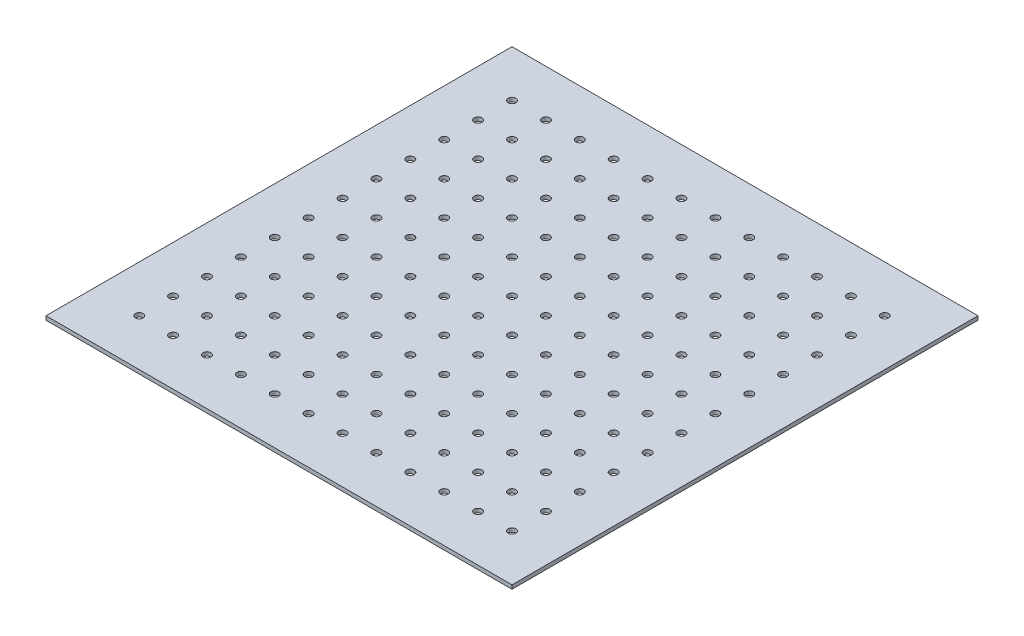
from build123d import *

# Parameters (mm, degrees)
SKETCH1_W           = 381
SKETCH1_H           = 381
SKETCH1_R           = 3.175
BOSS_EXTRUDE1_DEPTH = 3.175


with BuildPart() as part:
    # Sketch1 → Boss-Extrude1 (new body)
    with BuildSketch(Plane(origin=(0, 0, 0), x_dir=(1, 0, 0), z_dir=(0, 1, 0))):
        Rectangle(SKETCH1_W, SKETCH1_H)
        with Locations((-152.4, 152.4)):
            Circle(SKETCH1_R, mode=Mode.SUBTRACT)
        with Locations((-124.690909091, 152.4)):
            Circle(SKETCH1_R, mode=Mode.SUBTRACT)
        with Locations((-96.981818182, 152.4)):
            Circle(SKETCH1_R, mode=Mode.SUBTRACT)
        with Locations((-69.272727273, 152.4)):
            Circle(SKETCH1_R, mode=Mode.SUBTRACT)
        with Locations((-41.563636364, 152.4)):
            Circle(SKETCH1_R, mode=Mode.SUBTRACT)
        with Locations((-13.854545455, 152.4)):
            Circle(SKETCH1_R, mode=Mode.SUBTRACT)
        with Locations((13.854545455, 152.4)):
            Circle(SKETCH1_R, mode=Mode.SUBTRACT)
        with Locations((41.563636364, 152.4)):
            Circle(SKETCH1_R, mode=Mode.SUBTRACT)
        with Locations((69.272727273, 152.4)):
            Circle(SKETCH1_R, mode=Mode.SUBTRACT)
        with Locations((96.981818182, 152.4)):
            Circle(SKETCH1_R, mode=Mode.SUBTRACT)
        with Locations((124.690909091, 152.4)):
            Circle(SKETCH1_R, mode=Mode.SUBTRACT)
        with Locations((152.4, 152.4)):
            Circle(SKETCH1_R, mode=Mode.SUBTRACT)
        with Locations((-124.690909091, 124.690909091)):
            Circle(SKETCH1_R, mode=Mode.SUBTRACT)
        with Locations((-96.981818182, 124.690909091)):
            Circle(SKETCH1_R, mode=Mode.SUBTRACT)
        with Locations((-69.272727273, 124.690909091)):
            Circle(SKETCH1_R, mode=Mode.SUBTRACT)
        with Locations((-41.563636364, 124.690909091)):
            Circle(SKETCH1_R, mode=Mode.SUBTRACT)
        with Locations((-13.854545455, 124.690909091)):
            Circle(SKETCH1_R, mode=Mode.SUBTRACT)
        with Locations((13.854545455, 124.690909091)):
            Circle(SKETCH1_R, mode=Mode.SUBTRACT)
        with Locations((41.563636364, 124.690909091)):
            Circle(SKETCH1_R, mode=Mode.SUBTRACT)
        with Locations((69.272727273, 124.690909091)):
            Circle(SKETCH1_R, mode=Mode.SUBTRACT)
        with Locations((96.981818182, 124.690909091)):
            Circle(SKETCH1_R, mode=Mode.SUBTRACT)
        with Locations((124.690909091, 124.690909091)):
            Circle(SKETCH1_R, mode=Mode.SUBTRACT)
        with Locations((152.4, 124.690909091)):
            Circle(SKETCH1_R, mode=Mode.SUBTRACT)
        with Locations((-124.690909091, 96.981818182)):
            Circle(SKETCH1_R, mode=Mode.SUBTRACT)
        with Locations((-96.981818182, 96.981818182)):
            Circle(SKETCH1_R, mode=Mode.SUBTRACT)
        with Locations((-69.272727273, 96.981818182)):
            Circle(SKETCH1_R, mode=Mode.SUBTRACT)
        with Locations((-41.563636364, 96.981818182)):
            Circle(SKETCH1_R, mode=Mode.SUBTRACT)
        with Locations((-13.854545455, 96.981818182)):
            Circle(SKETCH1_R, mode=Mode.SUBTRACT)
        with Locations((13.854545455, 96.981818182)):
            Circle(SKETCH1_R, mode=Mode.SUBTRACT)
        with Locations((41.563636364, 96.981818182)):
            Circle(SKETCH1_R, mode=Mode.SUBTRACT)
        with Locations((69.272727273, 96.981818182)):
            Circle(SKETCH1_R, mode=Mode.SUBTRACT)
        with Locations((96.981818182, 96.981818182)):
            Circle(SKETCH1_R, mode=Mode.SUBTRACT)
        with Locations((124.690909091, 96.981818182)):
            Circle(SKETCH1_R, mode=Mode.SUBTRACT)
        with Locations((152.4, 96.981818182)):
            Circle(SKETCH1_R, mode=Mode.SUBTRACT)
        with Locations((-124.690909091, 69.272727273)):
            Circle(SKETCH1_R, mode=Mode.SUBTRACT)
        with Locations((-96.981818182, 69.272727273)):
            Circle(SKETCH1_R, mode=Mode.SUBTRACT)
        with Locations((-69.272727273, 69.272727273)):
            Circle(SKETCH1_R, mode=Mode.SUBTRACT)
        with Locations((-41.563636364, 69.272727273)):
            Circle(SKETCH1_R, mode=Mode.SUBTRACT)
        with Locations((-13.854545455, 69.272727273)):
            Circle(SKETCH1_R, mode=Mode.SUBTRACT)
        with Locations((13.854545455, 69.272727273)):
            Circle(SKETCH1_R, mode=Mode.SUBTRACT)
        with Locations((41.563636364, 69.272727273)):
            Circle(SKETCH1_R, mode=Mode.SUBTRACT)
        with Locations((69.272727273, 69.272727273)):
            Circle(SKETCH1_R, mode=Mode.SUBTRACT)
        with Locations((96.981818182, 69.272727273)):
            Circle(SKETCH1_R, mode=Mode.SUBTRACT)
        with Locations((124.690909091, 69.272727273)):
            Circle(SKETCH1_R, mode=Mode.SUBTRACT)
        with Locations((152.4, 69.272727273)):
            Circle(SKETCH1_R, mode=Mode.SUBTRACT)
        with Locations((-124.690909091, 41.563636364)):
            Circle(SKETCH1_R, mode=Mode.SUBTRACT)
        with Locations((-96.981818182, 41.563636364)):
            Circle(SKETCH1_R, mode=Mode.SUBTRACT)
        with Locations((-69.272727273, 41.563636364)):
            Circle(SKETCH1_R, mode=Mode.SUBTRACT)
        with Locations((-41.563636364, 41.563636364)):
            Circle(SKETCH1_R, mode=Mode.SUBTRACT)
        with Locations((-13.854545455, 41.563636364)):
            Circle(SKETCH1_R, mode=Mode.SUBTRACT)
        with Locations((13.854545455, 41.563636364)):
            Circle(SKETCH1_R, mode=Mode.SUBTRACT)
        with Locations((41.563636364, 41.563636364)):
            Circle(SKETCH1_R, mode=Mode.SUBTRACT)
        with Locations((69.272727273, 41.563636364)):
            Circle(SKETCH1_R, mode=Mode.SUBTRACT)
        with Locations((96.981818182, 41.563636364)):
            Circle(SKETCH1_R, mode=Mode.SUBTRACT)
        with Locations((124.690909091, 41.563636364)):
            Circle(SKETCH1_R, mode=Mode.SUBTRACT)
        with Locations((152.4, 41.563636364)):
            Circle(SKETCH1_R, mode=Mode.SUBTRACT)
        with Locations((-124.690909091, 13.854545455)):
            Circle(SKETCH1_R, mode=Mode.SUBTRACT)
        with Locations((-96.981818182, 13.854545455)):
            Circle(SKETCH1_R, mode=Mode.SUBTRACT)
        with Locations((-69.272727273, 13.854545455)):
            Circle(SKETCH1_R, mode=Mode.SUBTRACT)
        with Locations((-41.563636364, 13.854545455)):
            Circle(SKETCH1_R, mode=Mode.SUBTRACT)
        with Locations((-13.854545455, 13.854545455)):
            Circle(SKETCH1_R, mode=Mode.SUBTRACT)
        with Locations((13.854545455, 13.854545455)):
            Circle(SKETCH1_R, mode=Mode.SUBTRACT)
        with Locations((41.563636364, 13.854545455)):
            Circle(SKETCH1_R, mode=Mode.SUBTRACT)
        with Locations((69.272727273, 13.854545455)):
            Circle(SKETCH1_R, mode=Mode.SUBTRACT)
        with Locations((96.981818182, 13.854545455)):
            Circle(SKETCH1_R, mode=Mode.SUBTRACT)
        with Locations((124.690909091, 13.854545455)):
            Circle(SKETCH1_R, mode=Mode.SUBTRACT)
        with Locations((152.4, 13.854545455)):
            Circle(SKETCH1_R, mode=Mode.SUBTRACT)
        with Locations((-124.690909091, -13.854545455)):
            Circle(SKETCH1_R, mode=Mode.SUBTRACT)
        with Locations((-96.981818182, -13.854545455)):
            Circle(SKETCH1_R, mode=Mode.SUBTRACT)
        with Locations((-69.272727273, -13.854545455)):
            Circle(SKETCH1_R, mode=Mode.SUBTRACT)
        with Locations((-41.563636364, -13.854545455)):
            Circle(SKETCH1_R, mode=Mode.SUBTRACT)
        with Locations((-13.854545455, -13.854545455)):
            Circle(SKETCH1_R, mode=Mode.SUBTRACT)
        with Locations((13.854545455, -13.854545455)):
            Circle(SKETCH1_R, mode=Mode.SUBTRACT)
        with Locations((41.563636364, -13.854545455)):
            Circle(SKETCH1_R, mode=Mode.SUBTRACT)
        with Locations((69.272727273, -13.854545455)):
            Circle(SKETCH1_R, mode=Mode.SUBTRACT)
        with Locations((96.981818182, -13.854545455)):
            Circle(SKETCH1_R, mode=Mode.SUBTRACT)
        with Locations((124.690909091, -13.854545455)):
            Circle(SKETCH1_R, mode=Mode.SUBTRACT)
        with Locations((152.4, -13.854545455)):
            Circle(SKETCH1_R, mode=Mode.SUBTRACT)
        with Locations((-124.690909091, -41.563636364)):
            Circle(SKETCH1_R, mode=Mode.SUBTRACT)
        with Locations((-96.981818182, -41.563636364)):
            Circle(SKETCH1_R, mode=Mode.SUBTRACT)
        with Locations((-69.272727273, -41.563636364)):
            Circle(SKETCH1_R, mode=Mode.SUBTRACT)
        with Locations((-41.563636364, -41.563636364)):
            Circle(SKETCH1_R, mode=Mode.SUBTRACT)
        with Locations((-13.854545455, -41.563636364)):
            Circle(SKETCH1_R, mode=Mode.SUBTRACT)
        with Locations((13.854545455, -41.563636364)):
            Circle(SKETCH1_R, mode=Mode.SUBTRACT)
        with Locations((41.563636364, -41.563636364)):
            Circle(SKETCH1_R, mode=Mode.SUBTRACT)
        with Locations((69.272727273, -41.563636364)):
            Circle(SKETCH1_R, mode=Mode.SUBTRACT)
        with Locations((96.981818182, -41.563636364)):
            Circle(SKETCH1_R, mode=Mode.SUBTRACT)
        with Locations((124.690909091, -41.563636364)):
            Circle(SKETCH1_R, mode=Mode.SUBTRACT)
        with Locations((152.4, -41.563636364)):
            Circle(SKETCH1_R, mode=Mode.SUBTRACT)
        with Locations((-124.690909091, -69.272727273)):
            Circle(SKETCH1_R, mode=Mode.SUBTRACT)
        with Locations((-96.981818182, -69.272727273)):
            Circle(SKETCH1_R, mode=Mode.SUBTRACT)
        with Locations((-69.272727273, -69.272727273)):
            Circle(SKETCH1_R, mode=Mode.SUBTRACT)
        with Locations((-41.563636364, -69.272727273)):
            Circle(SKETCH1_R, mode=Mode.SUBTRACT)
        with Locations((-13.854545455, -69.272727273)):
            Circle(SKETCH1_R, mode=Mode.SUBTRACT)
        with Locations((13.854545455, -69.272727273)):
            Circle(SKETCH1_R, mode=Mode.SUBTRACT)
        with Locations((41.563636364, -69.272727273)):
            Circle(SKETCH1_R, mode=Mode.SUBTRACT)
        with Locations((69.272727273, -69.272727273)):
            Circle(SKETCH1_R, mode=Mode.SUBTRACT)
        with Locations((96.981818182, -69.272727273)):
            Circle(SKETCH1_R, mode=Mode.SUBTRACT)
        with Locations((124.690909091, -69.272727273)):
            Circle(SKETCH1_R, mode=Mode.SUBTRACT)
        with Locations((152.4, -69.272727273)):
            Circle(SKETCH1_R, mode=Mode.SUBTRACT)
        with Locations((-124.690909091, -96.981818182)):
            Circle(SKETCH1_R, mode=Mode.SUBTRACT)
        with Locations((-96.981818182, -96.981818182)):
            Circle(SKETCH1_R, mode=Mode.SUBTRACT)
        with Locations((-69.272727273, -96.981818182)):
            Circle(SKETCH1_R, mode=Mode.SUBTRACT)
        with Locations((-41.563636364, -96.981818182)):
            Circle(SKETCH1_R, mode=Mode.SUBTRACT)
        with Locations((-13.854545455, -96.981818182)):
            Circle(SKETCH1_R, mode=Mode.SUBTRACT)
        with Locations((13.854545455, -96.981818182)):
            Circle(SKETCH1_R, mode=Mode.SUBTRACT)
        with Locations((41.563636364, -96.981818182)):
            Circle(SKETCH1_R, mode=Mode.SUBTRACT)
        with Locations((69.272727273, -96.981818182)):
            Circle(SKETCH1_R, mode=Mode.SUBTRACT)
        with Locations((96.981818182, -96.981818182)):
            Circle(SKETCH1_R, mode=Mode.SUBTRACT)
        with Locations((124.690909091, -96.981818182)):
            Circle(SKETCH1_R, mode=Mode.SUBTRACT)
        with Locations((152.4, -96.981818182)):
            Circle(SKETCH1_R, mode=Mode.SUBTRACT)
        with Locations((-124.690909091, -124.690909091)):
            Circle(SKETCH1_R, mode=Mode.SUBTRACT)
        with Locations((-96.981818182, -124.690909091)):
            Circle(SKETCH1_R, mode=Mode.SUBTRACT)
        with Locations((-69.272727273, -124.690909091)):
            Circle(SKETCH1_R, mode=Mode.SUBTRACT)
        with Locations((-41.563636364, -124.690909091)):
            Circle(SKETCH1_R, mode=Mode.SUBTRACT)
        with Locations((-13.854545455, -124.690909091)):
            Circle(SKETCH1_R, mode=Mode.SUBTRACT)
        with Locations((13.854545455, -124.690909091)):
            Circle(SKETCH1_R, mode=Mode.SUBTRACT)
        with Locations((41.563636364, -124.690909091)):
            Circle(SKETCH1_R, mode=Mode.SUBTRACT)
        with Locations((69.272727273, -124.690909091)):
            Circle(SKETCH1_R, mode=Mode.SUBTRACT)
        with Locations((96.981818182, -124.690909091)):
            Circle(SKETCH1_R, mode=Mode.SUBTRACT)
        with Locations((124.690909091, -124.690909091)):
            Circle(SKETCH1_R, mode=Mode.SUBTRACT)
        with Locations((152.4, -124.690909091)):
            Circle(SKETCH1_R, mode=Mode.SUBTRACT)
        with Locations((-124.690909091, -152.4)):
            Circle(SKETCH1_R, mode=Mode.SUBTRACT)
        with Locations((-96.981818182, -152.4)):
            Circle(SKETCH1_R, mode=Mode.SUBTRACT)
        with Locations((-69.272727273, -152.4)):
            Circle(SKETCH1_R, mode=Mode.SUBTRACT)
        with Locations((-41.563636364, -152.4)):
            Circle(SKETCH1_R, mode=Mode.SUBTRACT)
        with Locations((-13.854545455, -152.4)):
            Circle(SKETCH1_R, mode=Mode.SUBTRACT)
        with Locations((13.854545455, -152.4)):
            Circle(SKETCH1_R, mode=Mode.SUBTRACT)
        with Locations((41.563636364, -152.4)):
            Circle(SKETCH1_R, mode=Mode.SUBTRACT)
        with Locations((69.272727273, -152.4)):
            Circle(SKETCH1_R, mode=Mode.SUBTRACT)
        with Locations((96.981818182, -152.4)):
            Circle(SKETCH1_R, mode=Mode.SUBTRACT)
        with Locations((124.690909091, -152.4)):
            Circle(SKETCH1_R, mode=Mode.SUBTRACT)
        with Locations((152.4, -152.4)):
            Circle(SKETCH1_R, mode=Mode.SUBTRACT)
        with Locations((-152.4, 124.690909091)):
            Circle(SKETCH1_R, mode=Mode.SUBTRACT)
        with Locations((-152.4, 96.981818182)):
            Circle(SKETCH1_R, mode=Mode.SUBTRACT)
        with Locations((-152.4, 69.272727273)):
            Circle(SKETCH1_R, mode=Mode.SUBTRACT)
        with Locations((-152.4, 41.563636364)):
            Circle(SKETCH1_R, mode=Mode.SUBTRACT)
        with Locations((-152.4, 13.854545455)):
            Circle(SKETCH1_R, mode=Mode.SUBTRACT)
        with Locations((-152.4, -13.854545455)):
            Circle(SKETCH1_R, mode=Mode.SUBTRACT)
        with Locations((-152.4, -41.563636364)):
            Circle(SKETCH1_R, mode=Mode.SUBTRACT)
        with Locations((-152.4, -69.272727273)):
            Circle(SKETCH1_R, mode=Mode.SUBTRACT)
        with Locations((-152.4, -96.981818182)):
            Circle(SKETCH1_R, mode=Mode.SUBTRACT)
        with Locations((-152.4, -124.690909091)):
            Circle(SKETCH1_R, mode=Mode.SUBTRACT)
        with Locations((-152.4, -152.4)):
            Circle(SKETCH1_R, mode=Mode.SUBTRACT)
    extrude(amount=BOSS_EXTRUDE1_DEPTH)


solid = part.part
